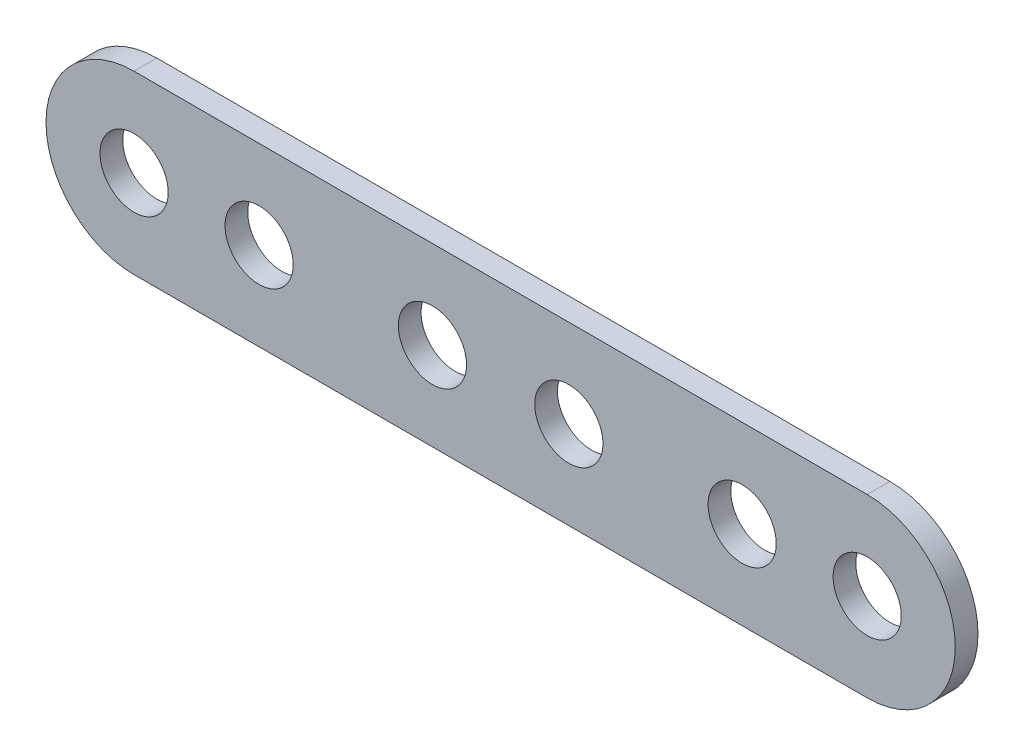
from build123d import *

# Parameters (mm, degrees)
SKETCH_1_R      = 3
EXTRUDE_1_DEPTH = 2


with BuildPart() as part:
    # Эскиз1 → Бобышка-Вытянуть1 (new body)
    with BuildSketch(Plane.XY):
        with BuildLine():
            Line((32.25, 7.75), (-32.25, 7.75))
            ThreePointArc((-32.25, 7.75), (-40, 0), (-32.25, -7.75))
            Line((-32.25, -7.75), (32.25, -7.75))
            ThreePointArc((32.25, -7.75), (40, 0), (32.25, 7.75))
        make_face()
        with Locations((-32.25, 0)):
            Circle(SKETCH_1_R, mode=Mode.SUBTRACT)
        with Locations((-21.25, 0)):
            Circle(SKETCH_1_R, mode=Mode.SUBTRACT)
        with Locations((-6, 0)):
            Circle(SKETCH_1_R, mode=Mode.SUBTRACT)
        with Locations((6, 0)):
            Circle(SKETCH_1_R, mode=Mode.SUBTRACT)
        with Locations((21.25, 0)):
            Circle(SKETCH_1_R, mode=Mode.SUBTRACT)
        with Locations((32.25, 0)):
            Circle(SKETCH_1_R, mode=Mode.SUBTRACT)
    extrude(amount=EXTRUDE_1_DEPTH)


solid = part.part
